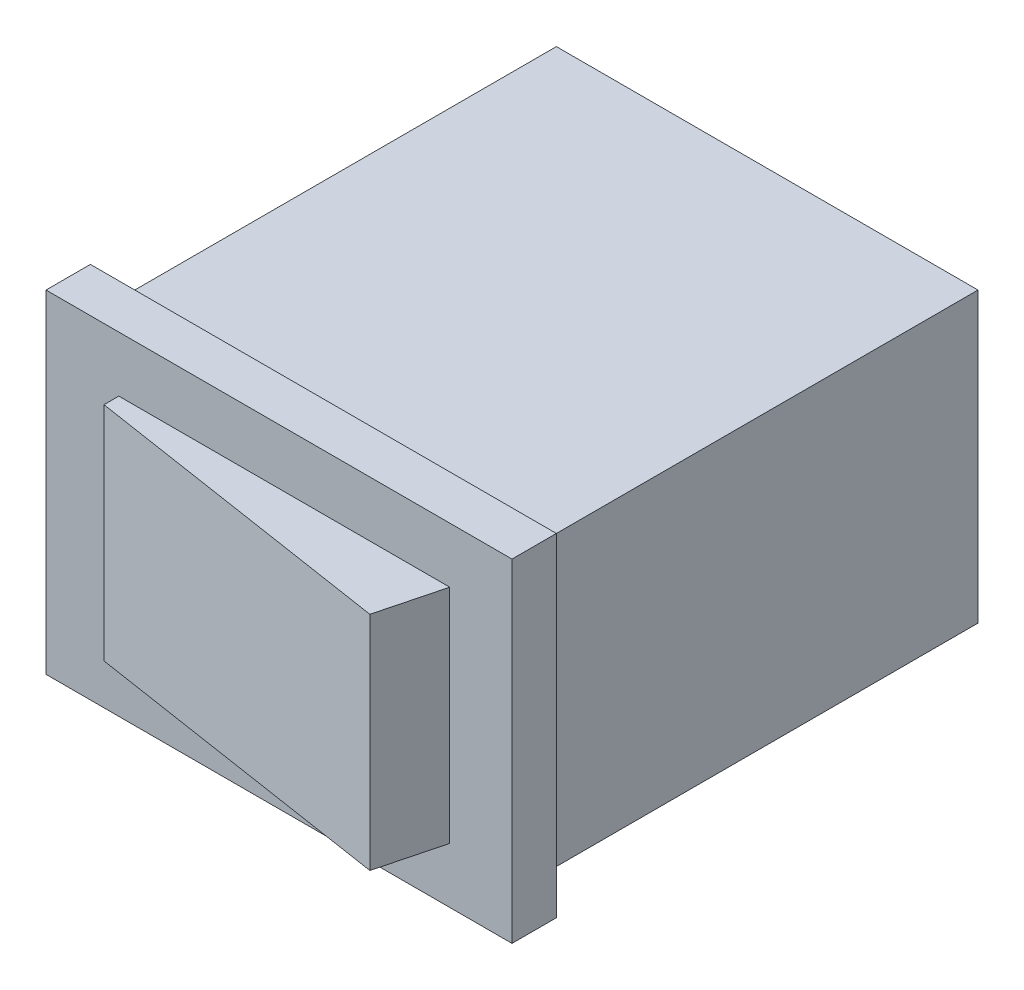
from build123d import *

# Parameters (mm, degrees)
SKETCH1_W                = 19
SKETCH1_H                = 13
BOSS_EXTRUDE1_DEPTH      = 20
SKETCH2_W                = 21
SKETCH2_H                = 15
BOSS_EXTRUDE2_DEPTH      = 2
BOSS_EXTRUDE3_DEPTH      = 5
BOSS_EXTRUDE3_DEPTH_BACK = 5


with BuildPart() as part:
    # Sketch1 → Boss-Extrude1 (new body)
    with BuildSketch(Plane.XY):
        Rectangle(SKETCH1_W, SKETCH1_H)
    extrude(amount=BOSS_EXTRUDE1_DEPTH)

    # Sketch2 → Boss-Extrude2 (add)
    with BuildSketch(Plane.XY.offset(20)):
        Rectangle(SKETCH2_W, SKETCH2_H)
    extrude(amount=BOSS_EXTRUDE2_DEPTH)

    # Sketch3 → Boss-Extrude3 (add, two sides)
    with BuildSketch(Plane(origin=(0, 0, 0), x_dir=(1, 0, 0), z_dir=(0, 1, 0))) as boss_extrude3_sk:
        Polygon((-7.218671047, -22), (-7.218671047, -22.66914067), (6.952686856, -24.857910608), (7.694642767, -22), align=None)
    extrude(amount=BOSS_EXTRUDE3_DEPTH)
    extrude(boss_extrude3_sk.sketch, amount=-BOSS_EXTRUDE3_DEPTH_BACK)


solid = part.part
